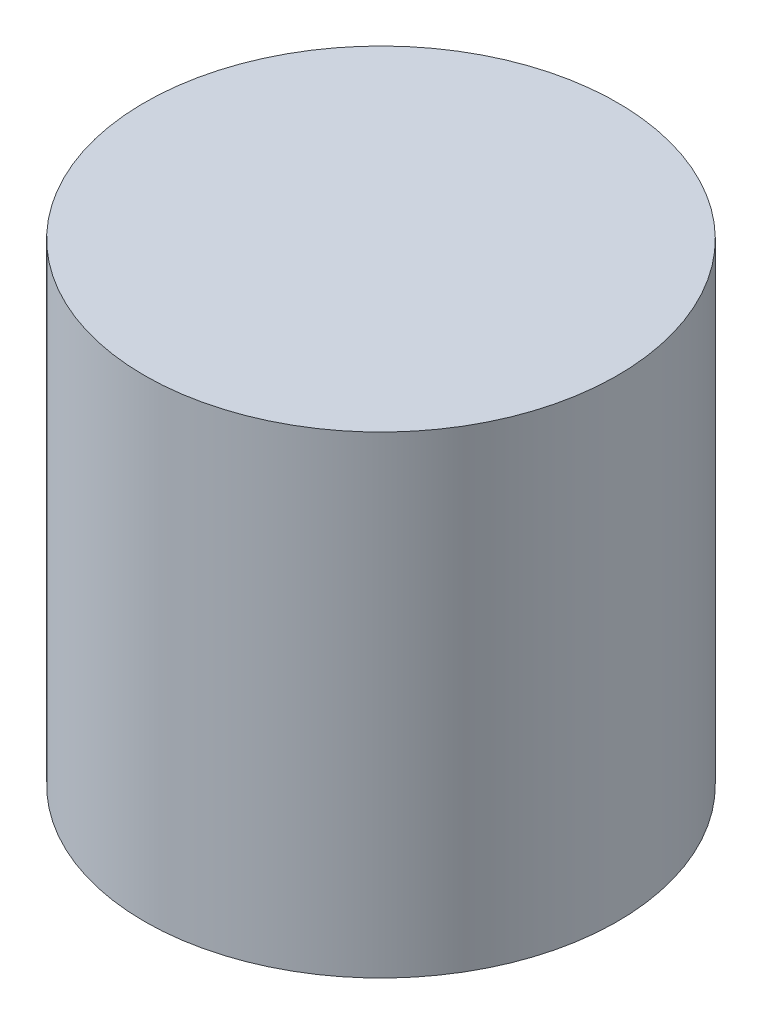
from build123d import *

# Parameters (mm, degrees)
SKETCH1_R           = 5
BOSS_EXTRUDE1_DEPTH = 10
SKETCH2_R           = 2.5
CUT_EXTRUDE1_DEPTH  = 5
SKETCH3_R           = 3
CUT_EXTRUDE2_DEPTH  = 1.5


with BuildPart() as part:
    # Sketch1 → Boss-Extrude1 (new body)
    with BuildSketch(Plane(origin=(0, 0, 0), x_dir=(1, 0, 0), z_dir=(0, 1, 0))):
        Circle(SKETCH1_R)
    extrude(amount=BOSS_EXTRUDE1_DEPTH)

    # Sketch2 → Cut-Extrude1 (cut)
    with BuildSketch(Plane.XZ):
        Circle(SKETCH2_R)
    extrude(amount=-CUT_EXTRUDE1_DEPTH, mode=Mode.SUBTRACT)

    # Sketch3 → Cut-Extrude2 (cut)
    with BuildSketch(Plane.XZ):
        Circle(SKETCH3_R)
    extrude(amount=-CUT_EXTRUDE2_DEPTH, mode=Mode.SUBTRACT)


solid = part.part
